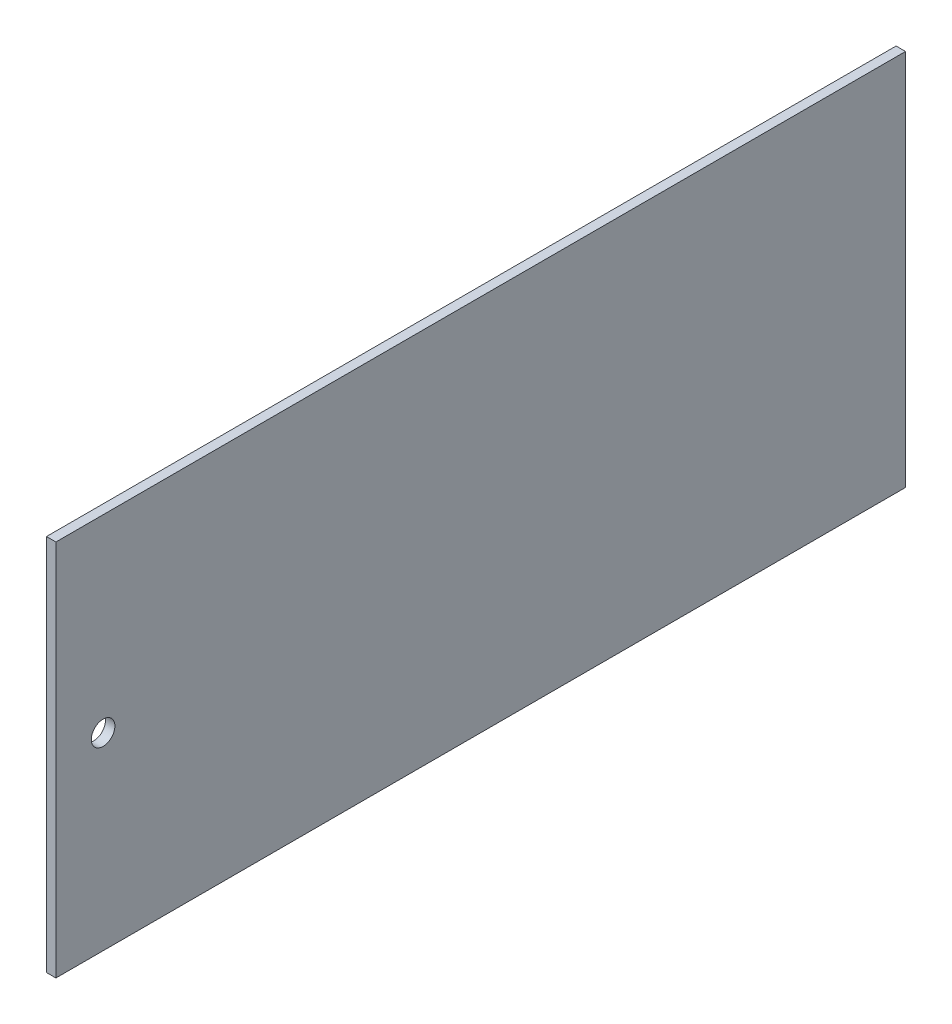
from build123d import *

# Parameters (mm, degrees)
SKETCH1_W           = 228.6
SKETCH1_H           = 101.6
BOSS_EXTRUDE1_DEPTH = 2.54
CUT_EXTRUDE1_REACH  = 4.54
SKETCH2_R           = 3.175


with BuildPart() as part:
    # Sketch1 → Boss-Extrude1 (new body)
    with BuildSketch(Plane(origin=(0, 0, 0), x_dir=(0, 0, -1), z_dir=(1, 0, 0))):
        Rectangle(SKETCH1_W, SKETCH1_H)
    extrude(amount=-BOSS_EXTRUDE1_DEPTH)

    # Sketch2 → Cut-Extrude1 (cut, up to next)
    with BuildSketch(Plane(origin=(0, 0, 0), x_dir=(0, 0, -1), z_dir=(1, 0, 0)), mode=Mode.PRIVATE) as cut_extrude1_sk1:
        with Locations((-101.6, 0)):
            Circle(SKETCH2_R)
    cut_extrude1_tool1 = extrude(cut_extrude1_sk1.sketch, amount=-CUT_EXTRUDE1_REACH, mode=Mode.PRIVATE) & part.part
    add(cut_extrude1_tool1.solids().sort_by_distance((0, 0, 101.6))[0], mode=Mode.SUBTRACT)


solid = part.part
